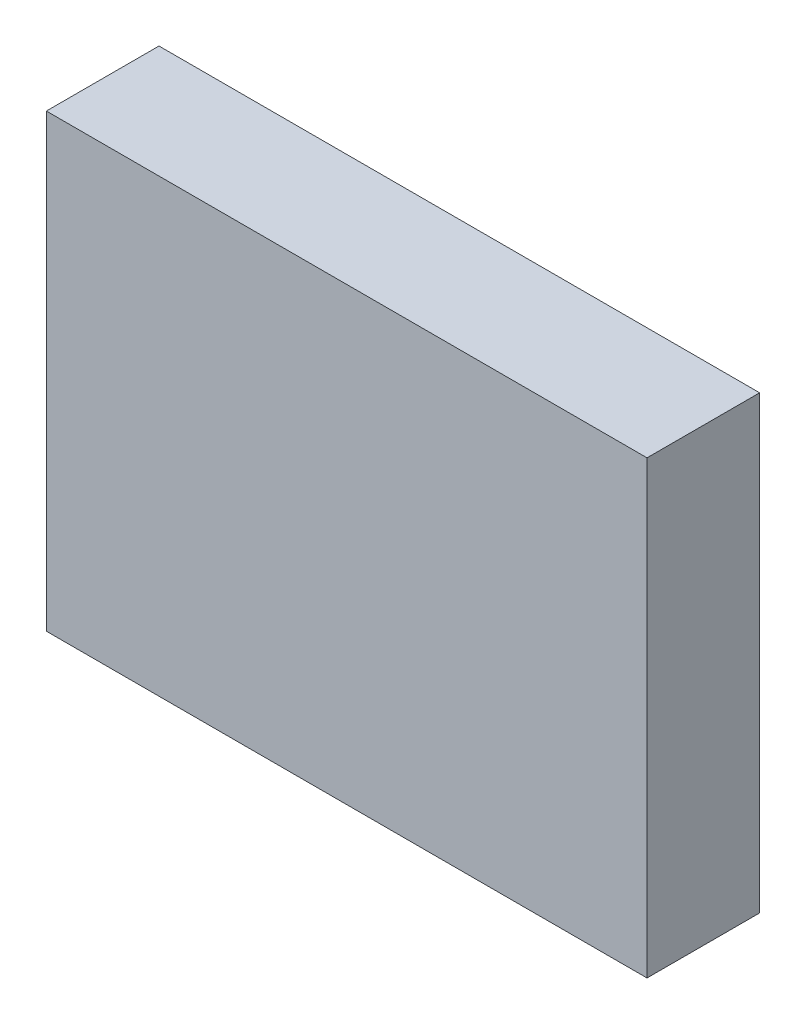
from build123d import *

# Parameters (mm, degrees)
SKETCH1_W           = 32
SKETCH1_H           = 24
BOSS_EXTRUDE1_DEPTH = 6


with BuildPart() as part:
    # Sketch1 → Boss-Extrude1 (new body)
    with BuildSketch(Plane.XY):
        Rectangle(SKETCH1_W, SKETCH1_H)
    extrude(amount=BOSS_EXTRUDE1_DEPTH)


solid = part.part
